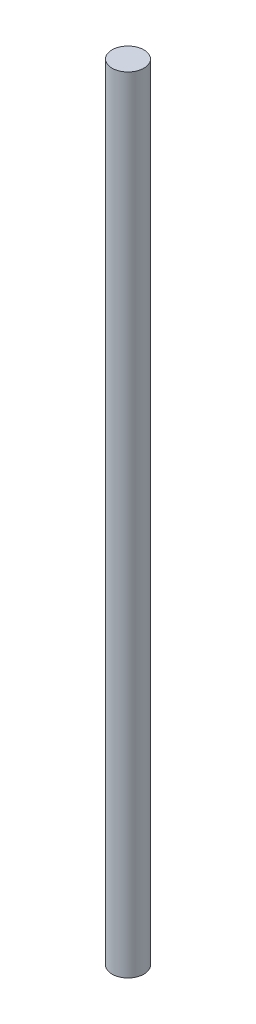
from build123d import *

# Parameters (mm, degrees)
SKETCH1_R           = 1.5
BOSS_EXTRUDE1_DEPTH = 74


with BuildPart() as part:
    # Sketch1 → Boss-Extrude1 (new body)
    with BuildSketch(Plane(origin=(0, 0, 0), x_dir=(1, 0, 0), z_dir=(0, 1, 0))):
        Circle(SKETCH1_R)
    extrude(amount=BOSS_EXTRUDE1_DEPTH)


solid = part.part
